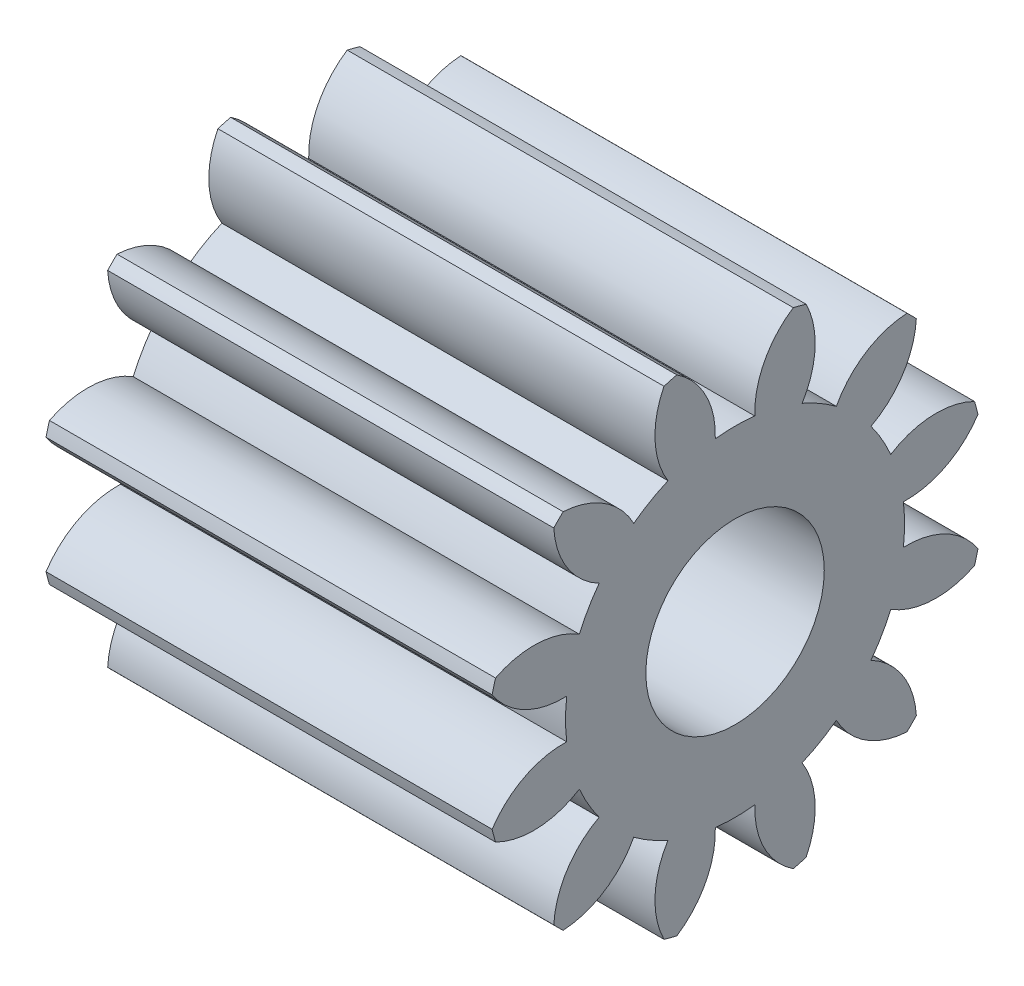
from build123d import *

# Parameters (mm, degrees)
BASPROSKE_W     = 100
BASPROSKE_H     = 56
TOOTHCUT_DEPTH  = 128.561749753
TEETHCUTS_COUNT = 12
TEETHCUTS_ANGLE = 330
BORSKE_R        = 20
BORE_DEPTH      = 100.0000508
SCALE1_SCALE    = 0.25


with BuildPart() as part:
    # BasProSke → Base-Revolve (revolve)
    with BuildSketch(Plane(origin=(0, 0, 0), x_dir=(1, 0, 0), z_dir=(0, 1, 0)), mode=Mode.PRIVATE) as base_revolve_sk:
        with Locations((50, 28)):
            Rectangle(BASPROSKE_W, BASPROSKE_H)
    revolve(base_revolve_sk.sketch.rotate(Axis((-10, 0, 0), (1, 0, 0)), 180), axis=Axis((-10, 0, 0), (1, 0, 0)))

    # TooCutSke → ToothCut (cut, through all)
    with BuildSketch(Plane(origin=(0, 0, 0), x_dir=(0, 0, -1), z_dir=(1, 0, 0))):
        with BuildLine():
            ThreePointArc((4.429508858, 37.739945049), (0, 37.999), (-4.429508858, 37.739945049))
            ThreePointArc((-4.429508858, 37.739945049), (-6.560078122, 47.242513828), (-13.078840191, 54.477420868))
            ThreePointArc((-13.078840191, 54.477420868), (0, 56.0254), (13.078840191, 54.477420868))
            ThreePointArc((13.078840191, 54.477420868), (6.560078122, 47.242513828), (4.429508858, 37.739945049))
        make_face()
    toothcut = extrude(amount=TOOTHCUT_DEPTH, mode=Mode.SUBTRACT)

    # TeethCuts: ToothCut ×12 about axis
    teethcuts_axis = Axis((-10, 0, 0), (1, 0, 0))
    for i in range(1, TEETHCUTS_COUNT):
        add(toothcut.rotate(teethcuts_axis, i * TEETHCUTS_ANGLE / (TEETHCUTS_COUNT - 1)), mode=Mode.SUBTRACT)

    # BorSke → Bore (cut, symmetric)
    with BuildSketch(Plane(origin=(0, 0, 0), x_dir=(0, 0, -1), z_dir=(1, 0, 0))):
        with Locations(Location((0, 0, 0), (0, 0, 180))):
            Circle(BORSKE_R)
    extrude(amount=BORE_DEPTH, both=True, mode=Mode.SUBTRACT)


with BuildPart() as part_1:
    # Scale1: scaled about (50, 0, 0)
    add(part.part.scale(SCALE1_SCALE).moved(Location((37.5, 0, 0))))


solid = part_1.part
